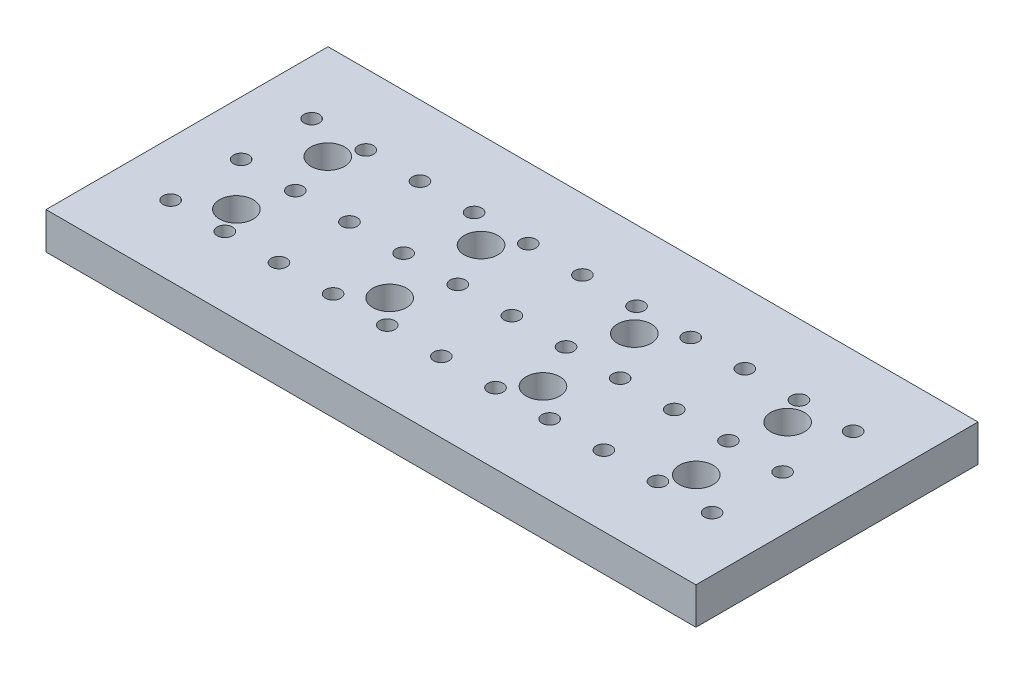
from build123d import *

# Parameters (mm, degrees)
SKETCH1_W                   = 106
SKETCH1_H                   = 46
BOSS_EXTRUDE1_DEPTH         = 6
M5_CLEARANCE_HOLE1_D        = 5.5
TAP_DRILL_FOR_M3X0_5_TAP1_D = 2.5


with BuildPart() as part:
    # Sketch1 → Boss-Extrude1 (new body)
    with BuildSketch(Plane(origin=(0, 0, 0), x_dir=(1, 0, 0), z_dir=(0, 1, 0))):
        with Locations((-19.22561214, 10.934191123)):
            Rectangle(SKETCH1_W, SKETCH1_H)
    extrude(amount=-BOSS_EXTRUDE1_DEPTH)

    # M5 Clearance Hole1 (through all)
    with Locations(Plane(origin=(-56.72561214, 0, -18.384191123), x_dir=(0, 0, 1), z_dir=(0, 1, 0))):
        with Locations((0, 0), (0, 25), (0, 50), (0, 75), (14.9, 75), (14.9, 50), (14.9, 25), (14.9, 0)):
            Hole(M5_CLEARANCE_HOLE1_D / 2)

    # Tap Drill for M3x0.5 Tap1 (through all)
    with Locations(Plane(origin=(-63.39561214, 0, 0.565808877), x_dir=(0, 0, 1), z_dir=(0, 1, 0))):
        with Locations((0, 0), (0, 8.83), (0, 26.49), (0, 35.32), (0, 52.98), (0, 44.15), (0, 17.66), (0, 61.81), (0, 70.64), (0, 79.47), (0, 88.3), (-23, 88.3), (-23, 79.47), (-23, 70.64), (-23, 61.81), (-23, 52.98), (-23, 44.15), (-23, 35.32), (-23, 26.49), (-23, 17.66), (-23, 8.83), (-23, 0), (-11.5, 0), (-11.5, 8.83), (-11.5, 17.66), (-11.5, 26.49), (-11.5, 52.98), (-11.5, 61.81), (-11.5, 79.47), (-11.5, 88.3), (-11.5, 35.32), (-11.5, 70.64), (-11.5, 44.15)):
            Hole(TAP_DRILL_FOR_M3X0_5_TAP1_D / 2)


solid = part.part
